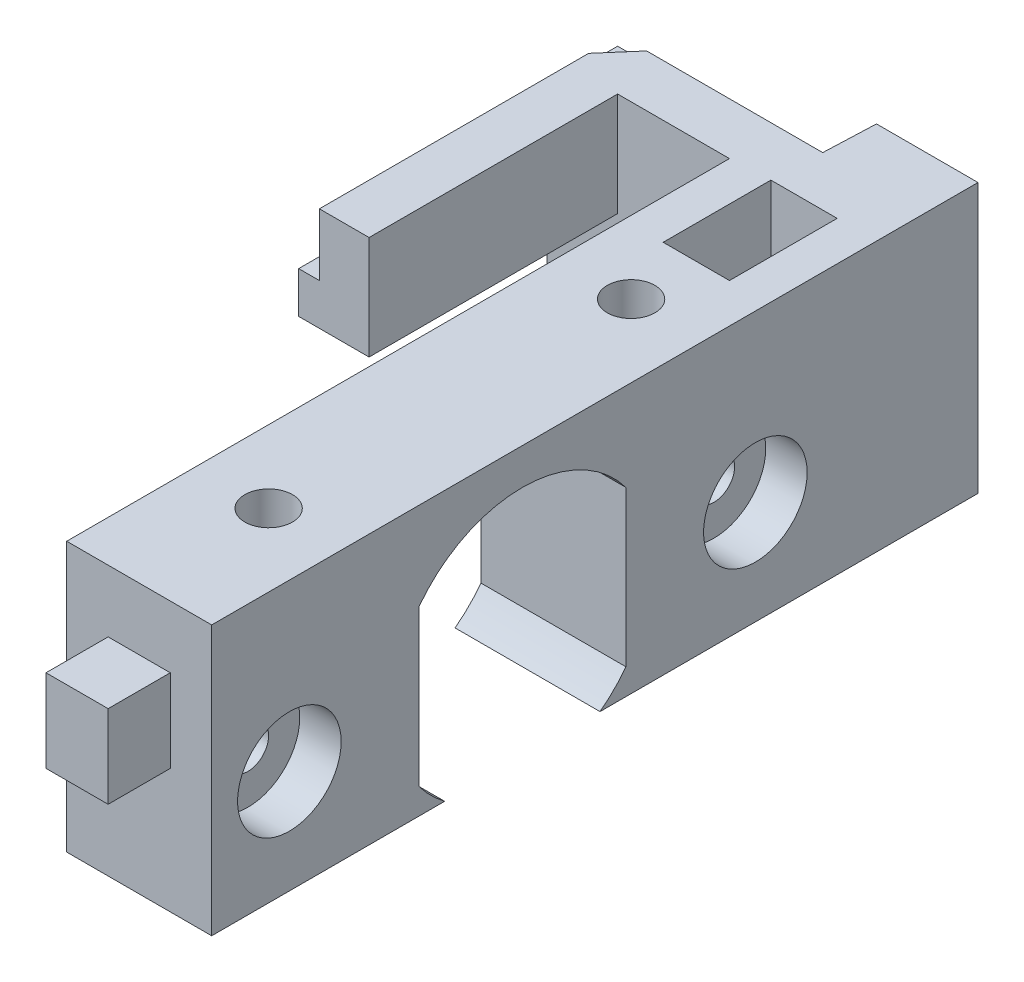
from build123d import *

# Parameters (mm, degrees)
SKETCH2_R           = 1
BOSS_EXTRUDE1_DEPTH = 7
CUT_EXTRUDE1_START  = -5
SKETCH3_R           = 1.15
CUT_EXTRUDE1_DEPTH  = 13
SKETCH5_R           = 2.5
CUT_EXTRUDE2_DEPTH  = 2
CUT_EXTRUDE3_START  = 7
SKETCH5_2_R         = 2.5
CUT_EXTRUDE3_DEPTH  = 2
BOSS_EXTRUDE2_START = -5
BOSS_EXTRUDE2_DEPTH = 13
CUT_EXTRUDE4_START  = -5.4
SKETCH7_W           = 12
SKETCH7_H           = 6
CUT_EXTRUDE4_DEPTH  = 5
CUT_EXTRUDE5_START  = -10.4
SKETCH8_W           = 15
SKETCH8_H           = 13
CUT_EXTRUDE5_DEPTH  = 1.6
CUT_EXTRUDE6_START  = -8.8
SKETCH9_W           = 13
SKETCH9_H           = 3
CUT_EXTRUDE6_DEPTH  = 1
BOSS_EXTRUDE4_START = 8
SKETCH10_W          = 5.4
SKETCH10_H          = 5
BOSS_EXTRUDE4_DEPTH = 13
CUT_EXTRUDE7_START  = 8
SKETCH11_W          = 17.4
SKETCH11_H          = 3
CUT_EXTRUDE7_DEPTH  = 13
BOSS_EXTRUDE5_START = 15
SKETCH12_W          = 3
SKETCH12_H          = 4
BOSS_EXTRUDE5_DEPTH = 3
CUT_EXTRUDE8_START  = 8
CUT_EXTRUDE8_DEPTH  = 13
CUT_EXTRUDE9_START  = 8
CUT_EXTRUDE9_DEPTH  = 3
CUT_EXTRUDE10_START = 8
SKETCH15_W          = 3.2
SKETCH15_H          = 5.2
CUT_EXTRUDE10_DEPTH = 3.2


with BuildPart() as part:
    # Sketch2 → Boss-Extrude1 (new body)
    with BuildSketch(Plane(origin=(0, 0, 0), x_dir=(0, 0, -1), z_dir=(1, 0, 0))):
        with BuildLine():
            Line((3.75, -5), (15, -5))
            Line((15, -5), (15, 8))
            Line((15, 8), (-15, 8))
            Line((-15, 8), (-15, -5))
            Line((-15, -5), (-3.75, -5))
            ThreePointArc((-3.75, -5), (-4.419417382, -4.419417382), (-5, -3.75))
            Line((-5, -3.75), (-5, 3.75))
            ThreePointArc((-5, 3.75), (0, 6.25), (5, 3.75))
            Line((5, 3.75), (5, -3.75))
            ThreePointArc((5, -3.75), (4.419417382, -4.419417382), (3.75, -5))
        make_face()
        with Locations((-11.25, 0)):
            Circle(SKETCH2_R, mode=Mode.SUBTRACT)
        with Locations((11.25, 0)):
            Circle(SKETCH2_R, mode=Mode.SUBTRACT)
    extrude(amount=BOSS_EXTRUDE1_DEPTH)

    # Sketch3 → Cut-Extrude1 (cut)
    with BuildSketch(Plane(origin=(0, 0, 0), x_dir=(1, 0, 0), z_dir=(0, 1, 0)).offset(CUT_EXTRUDE1_START)):
        with Locations((3.5, 8.75)):
            Circle(SKETCH3_R)
        with Locations((3.5, -8.75)):
            Circle(SKETCH3_R)
    extrude(amount=CUT_EXTRUDE1_DEPTH, mode=Mode.SUBTRACT)

    # Sketch5 → Cut-Extrude2 (cut)
    with BuildSketch(Plane(origin=(0, 0, 0), x_dir=(0, 0, -1), z_dir=(1, 0, 0))):
        with Locations((11.25, 0)):
            Circle(SKETCH5_R)
        with Locations((-11.25, 0)):
            Circle(SKETCH5_R)
    extrude(amount=CUT_EXTRUDE2_DEPTH, mode=Mode.SUBTRACT)

    # Sketch5_2 → Cut-Extrude3 (cut)
    with BuildSketch(Plane(origin=(0, 0, 0), x_dir=(0, 0, -1), z_dir=(1, 0, 0)).offset(CUT_EXTRUDE3_START)):
        with Locations((11.25, 0)):
            Circle(SKETCH5_2_R)
        with Locations((-11.25, 0)):
            Circle(SKETCH5_2_R)
    extrude(amount=-CUT_EXTRUDE3_DEPTH, mode=Mode.SUBTRACT)

    # Sketch6 → Boss-Extrude2 (add)
    with BuildSketch(Plane(origin=(0, 0, 0), x_dir=(1, 0, 0), z_dir=(0, 1, 0)).offset(BOSS_EXTRUDE2_START)):
        Polygon((7, 15), (7, 25), (-10.4, 25), (-10.4, 5), (-5.4, 5), (-5.4, 22), (0, 22), (0, 15), align=None)
    extrude(amount=BOSS_EXTRUDE2_DEPTH)

    # Sketch7 → Cut-Extrude4 (cut)
    with BuildSketch(Plane(origin=(0, 0, 0), x_dir=(0, 0, -1), z_dir=(1, 0, 0)).offset(CUT_EXTRUDE4_START)):
        with Locations((11, 0)):
            Rectangle(SKETCH7_W, SKETCH7_H)
    extrude(amount=-CUT_EXTRUDE4_DEPTH, mode=Mode.SUBTRACT)

    # Sketch8 → Cut-Extrude5 (cut)
    with BuildSketch(Plane(origin=(0, 0, 0), x_dir=(0, 0, -1), z_dir=(1, 0, 0)).offset(CUT_EXTRUDE5_START)):
        with Locations((12.5, 1.5)):
            Rectangle(SKETCH8_W, SKETCH8_H)
    extrude(amount=CUT_EXTRUDE5_DEPTH, mode=Mode.SUBTRACT)

    # Sketch9 → Cut-Extrude6 (cut)
    with BuildSketch(Plane(origin=(0, 0, 0), x_dir=(0, 0, -1), z_dir=(1, 0, 0)).offset(CUT_EXTRUDE6_START)):
        with Locations((11.5, 6.5)):
            Rectangle(SKETCH9_W, SKETCH9_H)
    extrude(amount=CUT_EXTRUDE6_DEPTH, mode=Mode.SUBTRACT)

    # Sketch10 → Boss-Extrude4 (add)
    with BuildSketch(Plane(origin=(0, 0, 0), x_dir=(1, 0, 0), z_dir=(0, 1, 0)).offset(BOSS_EXTRUDE4_START)):
        with Locations((-2.7, 19.5)):
            Rectangle(SKETCH10_W, SKETCH10_H)
    extrude(amount=-BOSS_EXTRUDE4_DEPTH)

    # Sketch11 → Cut-Extrude7 (cut)
    with BuildSketch(Plane(origin=(0, 0, 0), x_dir=(1, 0, 0), z_dir=(0, 1, 0)).offset(CUT_EXTRUDE7_START)):
        with Locations((-1.7, 23.5)):
            Rectangle(SKETCH11_W, SKETCH11_H)
    extrude(amount=-CUT_EXTRUDE7_DEPTH, mode=Mode.SUBTRACT)

    # Sketch12 → Boss-Extrude5 (add)
    with BuildSketch(Plane.XY.offset(BOSS_EXTRUDE5_START)):
        with Locations((3.5, 3)):
            Rectangle(SKETCH12_W, SKETCH12_H)
    extrude(amount=BOSS_EXTRUDE5_DEPTH)

    # Sketch13 → Cut-Extrude8 (cut)
    with BuildSketch(Plane(origin=(0, 0, 0), x_dir=(1, 0, 0), z_dir=(0, 1, 0)).offset(CUT_EXTRUDE8_START)):
        Polygon((2.1, 22), (2.000079904, 19.501997603), (-6.499920096, 19.501997603), (-7.9, 22), align=None)
    extrude(amount=-CUT_EXTRUDE8_DEPTH, mode=Mode.SUBTRACT)

    # Sketch14 → Cut-Extrude9 (cut)
    with BuildSketch(Plane(origin=(0, 0, 0), x_dir=(1, 0, 0), z_dir=(0, 1, 0)).offset(CUT_EXTRUDE9_START)):
        Polygon((-6.499920096, 19.501997603), (-7.8, 18), (-8.8, 18), (-8.8, 20), (-10.4, 20), (-10.4, 22), (-7.9, 22), align=None)
    extrude(amount=-CUT_EXTRUDE9_DEPTH, mode=Mode.SUBTRACT)

    # Sketch15 → Cut-Extrude10 (cut)
    with BuildSketch(Plane(origin=(0, 0, 0), x_dir=(1, 0, 0), z_dir=(0, 1, 0)).offset(CUT_EXTRUDE10_START)):
        with Locations((3.5, 14.5)):
            Rectangle(SKETCH15_W, SKETCH15_H)
    extrude(amount=-CUT_EXTRUDE10_DEPTH, mode=Mode.SUBTRACT)


solid = part.part
